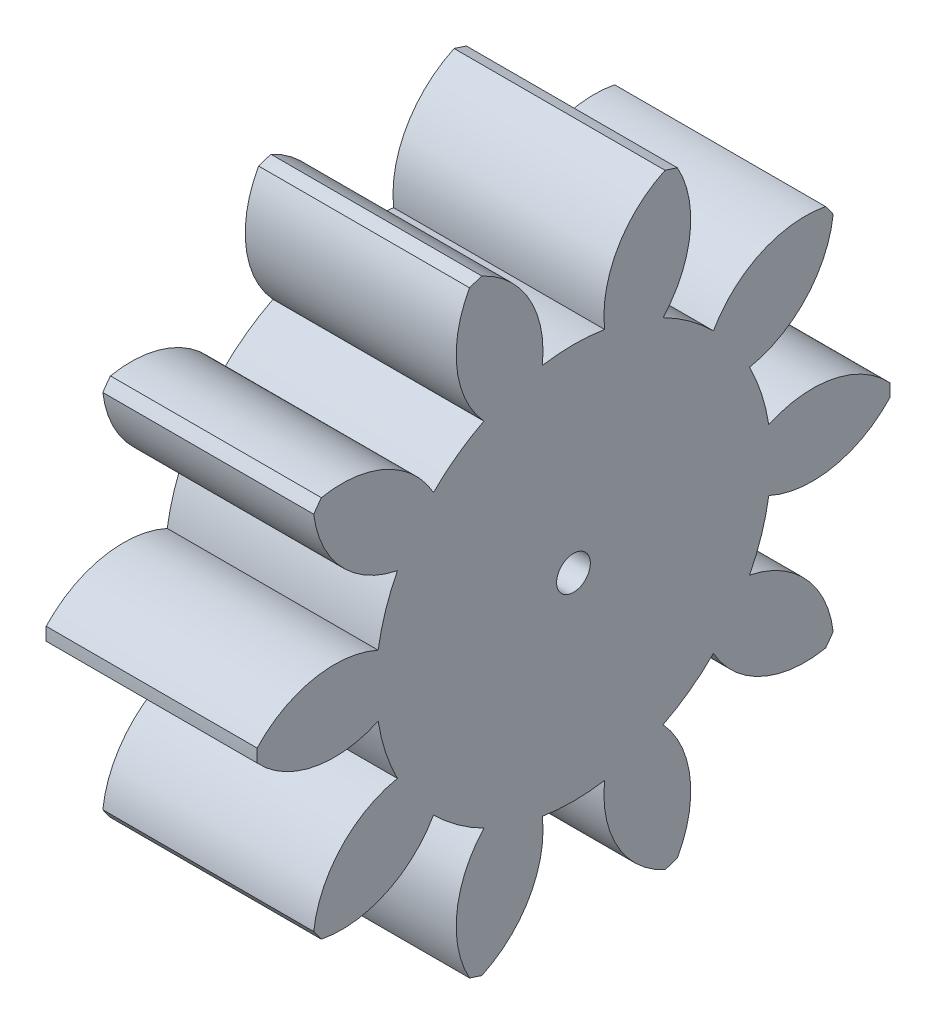
from build123d import *

# Parameters (mm, degrees)
BASPROSKE_W              = 12
BASPROSKE_H              = 7.5
TOOTHCUT_DEPTH           = 17.015617378
TEETHCUTS_COUNT          = 10
TEETHCUTS_ANGLE          = 324
BORSKE_R                 = 0.4
BORE_DEPTH               = 50.0000508
SCHIZZO1_W               = 18.724630976
SCHIZZO1_H               = 16.705622174
TAGLIO_ESTRUSIONE1_DEPTH = 7


with BuildPart() as part:
    # BasProSke → Base-Revolve (revolve)
    with BuildSketch(Plane(origin=(0, 0, 0), x_dir=(1, 0, 0), z_dir=(0, 1, 0)), mode=Mode.PRIVATE) as base_revolve_sk:
        with Locations((6, 3.75)):
            Rectangle(BASPROSKE_W, BASPROSKE_H)
    revolve(base_revolve_sk.sketch.rotate(Axis((-10, 0, 0), (1, 0, 0)), 180), axis=Axis((-10, 0, 0), (1, 0, 0)))

    # TooCutSke → ToothCut (cut, through all)
    with BuildSketch(Plane(origin=(0, 0, 0), x_dir=(0, 0, -1), z_dir=(1, 0, 0))):
        with BuildLine():
            ThreePointArc((0.737676151, 4.628079099), (0, 4.6865), (-0.737676151, 4.628079099))
            ThreePointArc((-0.737676151, 4.628079099), (-1.051542781, 6.151798382), (-2.205760267, 7.194877817))
            ThreePointArc((-2.205760267, 7.194877817), (0, 7.5254), (2.205760267, 7.194877817))
            ThreePointArc((2.205760267, 7.194877817), (1.051542781, 6.151798382), (0.737676151, 4.628079099))
        make_face()
    toothcut = extrude(amount=TOOTHCUT_DEPTH, mode=Mode.SUBTRACT)

    # TeethCuts: ToothCut ×10 about axis
    teethcuts_axis = Axis((-10, 0, 0), (1, 0, 0))
    for i in range(1, TEETHCUTS_COUNT):
        add(toothcut.rotate(teethcuts_axis, i * TEETHCUTS_ANGLE / (TEETHCUTS_COUNT - 1)), mode=Mode.SUBTRACT)

    # BorSke → Bore (cut, symmetric)
    with BuildSketch(Plane(origin=(0, 0, 0), x_dir=(0, 0, -1), z_dir=(1, 0, 0))):
        with Locations(Location((0, 0, 0), (0, 0, 180))):
            Circle(BORSKE_R)
    extrude(amount=BORE_DEPTH, both=True, mode=Mode.SUBTRACT)

    # Schizzo1 → Taglio-Estrusione1 (cut)
    with BuildSketch(Plane(origin=(12, 0, 0), x_dir=(0, 0, -1), z_dir=(1, 0, 0))):
        Rectangle(SCHIZZO1_W, SCHIZZO1_H)
    extrude(amount=-TAGLIO_ESTRUSIONE1_DEPTH, mode=Mode.SUBTRACT)


solid = part.part
